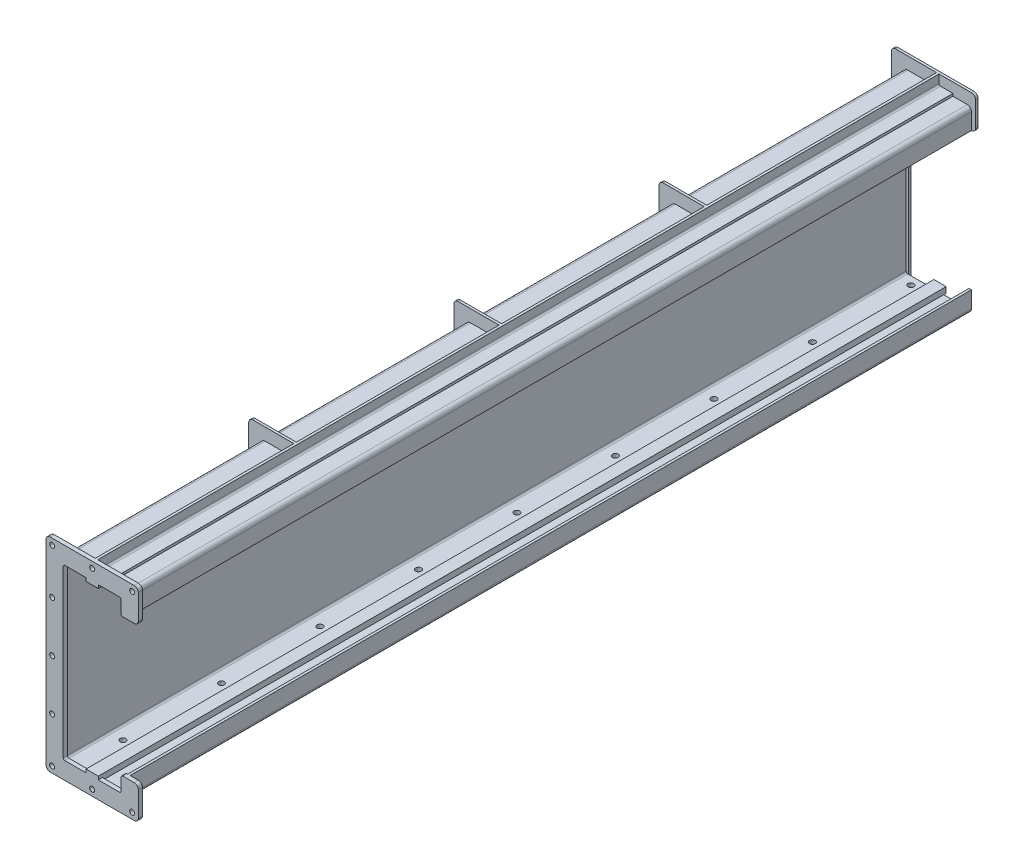
from build123d import *

# Parameters (mm, degrees)
EXTRUDE_1_DEPTH     = 2050
EXTRUDE_2_DEPTH     = 10
SKETCH_3_W          = 40
SKETCH_3_H          = 2050
EXTRUDE_3_DEPTH     = 6
SKETCH_4_W          = 6
SKETCH_4_H          = 2050
EXTRUDE_4_DEPTH     = 24
FILLET_1_R          = 4
FILLET_2_R          = 10
EXTRUDE_5_DEPTH     = 6
EXTRUDE_6_DEPTH     = 6
EXTRUDE_7_DEPTH     = 6
EXTRUDE_8_DEPTH     = 6
SKETCH_9_W          = 180
SKETCH_9_H          = 2056
EXTRUDE_9_DEPTH     = 6
SKETCH_10_W         = 30
SKETCH_10_H         = 14
EXTRUDE_10_DEPTH    = 2066
SKETCH_11_R         = 7
CUT_EXTRUDE_1_DEPTH = 37
SKETCH_13_R         = 6
CUT_EXTRUDE_2_DEPTH = 10


with BuildPart() as part:
    # 草图1 → 凸台-拉伸1 (new body)
    with BuildSketch(Plane.XY):
        with BuildLine():
            Line((10, 430), (155, 430))
            ThreePointArc((155, 430), (157.828427125, 428.828427125), (159, 426))
            Line((159, 426), (159, 386))
            Line((159, 386), (165, 386))
            Line((165, 386), (165, 426))
            ThreePointArc((165, 426), (162.071067812, 433.071067812), (155, 436))
            Line((155, 436), (10, 436))
            ThreePointArc((10, 436), (2.928932188, 433.071067812), (0, 426))
            Line((0, 426), (0, 10))
            ThreePointArc((0, 10), (2.928932188, 2.928932188), (10, 0))
            Line((10, 0), (155, 0))
            ThreePointArc((155, 0), (162.071067812, 2.928932188), (165, 10))
            Line((165, 10), (165, 50))
            Line((165, 50), (159, 50))
            Line((159, 50), (159, 10))
            ThreePointArc((159, 10), (157.828427125, 7.171572875), (155, 6))
            Line((155, 6), (10, 6))
            ThreePointArc((10, 6), (7.171572875, 7.171572875), (6, 10))
            Line((6, 10), (6, 426))
            ThreePointArc((6, 426), (7.171572875, 428.828427125), (10, 430))
        make_face()
    extrude(amount=EXTRUDE_1_DEPTH)



with BuildPart() as body_2:
    # 草图2 → 凸台-拉伸2 (new body)
    with BuildSketch(Plane.XY.offset(2050)):
        with BuildLine():
            Line((185, 466), (-20, 466))
            ThreePointArc((-20, 466), (-27.071067812, 463.071067812), (-30, 456))
            Line((-30, 456), (-30, -20))
            ThreePointArc((-30, -20), (-27.071067812, -27.071067812), (-20, -30))
            Line((-20, -30), (185, -30))
            ThreePointArc((185, -30), (192.071067812, -27.071067812), (195, -20))
            Line((195, -20), (195, 40))
            ThreePointArc((195, 40), (192.071067812, 47.071067812), (185, 50))
            Line((185, 50), (157, 50))
            ThreePointArc((157, 50), (154.171572875, 48.828427125), (153, 46))
            Line((153, 46), (153, 16))
            ThreePointArc((153, 16), (151.828427125, 13.171572875), (149, 12))
            Line((149, 12), (16, 12))
            ThreePointArc((16, 12), (13.171572875, 13.171572875), (12, 16))
            Line((12, 16), (12, 420))
            ThreePointArc((12, 420), (13.171572875, 422.828427125), (16, 424))
            Line((16, 424), (149, 424))
            ThreePointArc((149, 424), (151.828427125, 422.828427125), (153, 420))
            Line((153, 420), (153, 390))
            ThreePointArc((153, 390), (154.171572875, 387.171572875), (157, 386))
            Line((157, 386), (185, 386))
            ThreePointArc((185, 386), (192.071067812, 388.928932188), (195, 396))
            Line((195, 396), (195, 456))
            ThreePointArc((195, 456), (192.071067812, 463.071067812), (185, 466))
        make_face()
    extrude(amount=EXTRUDE_2_DEPTH)



with BuildPart() as body_3:
    # 草图3 → 凸台-拉伸3 (new body)
    with BuildSketch(Plane(origin=(0, 436, 0), x_dir=(1, 0, 0), z_dir=(0, 1, 0))):
        with Locations((100, -1025)):
            Rectangle(SKETCH_3_W, SKETCH_3_H)
    extrude(amount=EXTRUDE_3_DEPTH)


with BuildPart() as body_2_1:
    add(body_2.part)

    add(body_3.part)  # 凸台-拉伸4 merges body 3
    # 草图4 → 凸台-拉伸4 (add)
    with BuildSketch(Plane(origin=(0, 442, 0), x_dir=(1, 0, 0), z_dir=(0, 1, 0))):
        with Locations((83, -1025)):
            Rectangle(SKETCH_4_W, SKETCH_4_H)
    extrude(amount=EXTRUDE_4_DEPTH)

    # 圆角1
    fillet_1_edges = [body_2_1.edges().sort_by_distance(p)[0] for p in [
        (86, 442, 1025),
    ]]
    fillet(fillet_1_edges, radius=FILLET_1_R)

    # 圆角2
    fillet_2_edges = [body_2_1.edges().sort_by_distance(p)[0] for p in [
        (80, 436, 1025),
    ]]
    fillet(fillet_2_edges, radius=FILLET_2_R)


with BuildPart() as part_1:
    add(part.part)

    add(body_2_1.part)  # 凸台-拉伸5 merges body 2
    # 草图5 → 凸台-拉伸5 (add)
    with BuildSketch(Plane.XY.offset(1560)):
        with BuildLine():
            Line((0, 0), (-20, 0))
            ThreePointArc((-20, 0), (-27.071067812, 2.928932188), (-30, 10))
            Line((-30, 10), (-30, 456))
            ThreePointArc((-30, 456), (-27.071067812, 463.071067812), (-20, 466))
            Line((-20, 466), (80, 466))
            Line((80, 466), (80, 436))
            Line((80, 436), (10, 436))
            ThreePointArc((10, 436), (2.928932188, 433.071067812), (0, 426))
            Line((0, 426), (0, 0))
        make_face()
    extrude(amount=EXTRUDE_5_DEPTH)

    # 草图6 → 凸台-拉伸6 (add)
    with BuildSketch(Plane.XY.offset(1060)):
        with BuildLine():
            Line((0, 0), (0, 10))
            Line((0, 10), (0, 426))
            ThreePointArc((0, 426), (2.928932188, 433.071067812), (10, 436))
            Line((10, 436), (80, 436))
            Line((80, 436), (80, 446))
            Line((80, 446), (80, 466))
            Line((80, 466), (-20, 466))
            ThreePointArc((-20, 466), (-27.071067812, 463.071067812), (-30, 456))
            Line((-30, 456), (-30, 10))
            ThreePointArc((-30, 10), (-27.071067812, 2.928932188), (-20, 0))
            Line((-20, 0), (0, 0))
        make_face()
    extrude(amount=EXTRUDE_6_DEPTH)

    # 草图7 → 凸台-拉伸7 (add)
    with BuildSketch(Plane.XY.offset(560)):
        with BuildLine():
            Line((0, 10), (0, 426))
            ThreePointArc((0, 426), (2.928932188, 433.071067812), (10, 436))
            Line((10, 436), (80, 436))
            Line((80, 436), (80, 446))
            Line((80, 446), (80, 466))
            Line((80, 466), (-20, 466))
            ThreePointArc((-20, 466), (-27.071067812, 463.071067812), (-30, 456))
            Line((-30, 456), (-30, 10))
            ThreePointArc((-30, 10), (-27.071067812, 2.928932188), (-20, 0))
            Line((-20, 0), (0, 0))
            Line((0, 0), (0, 10))
        make_face()
    extrude(amount=EXTRUDE_7_DEPTH)

    # 草图8 → 凸台-拉伸8 (add)
    with BuildSketch(Plane(origin=(0, 0, 0), x_dir=(-1, 0, 0), z_dir=(0, 0, -1))):
        with BuildLine():
            Line((-12, 0), (30, 0))
            Line((30, 0), (30, 456))
            ThreePointArc((30, 456), (27.071067812, 463.071067812), (20, 466))
            Line((20, 466), (-165, 466))
            ThreePointArc((-165, 466), (-172.071067812, 463.071067812), (-175, 456))
            Line((-175, 456), (-175, 396))
            ThreePointArc((-175, 396), (-172.071067812, 388.928932188), (-165, 386))
            Line((-165, 386), (-157, 386))
            ThreePointArc((-157, 386), (-154.171572875, 387.171572875), (-153, 390))
            Line((-153, 390), (-153, 420))
            ThreePointArc((-153, 420), (-151.828427125, 422.828427125), (-149, 424))
            Line((-149, 424), (-16, 424))
            ThreePointArc((-16, 424), (-13.171572875, 422.828427125), (-12, 420))
            Line((-12, 420), (-12, 0))
        make_face()
    extrude(amount=EXTRUDE_8_DEPTH)

    # 草图9 → 凸台-拉伸9 (add)
    with BuildSketch(Plane.XZ):
        with Locations((60, 1022)):
            Rectangle(SKETCH_9_W, SKETCH_9_H)
    extrude(amount=EXTRUDE_9_DEPTH)

    # 草图10 → 凸台-拉伸10 (add)
    with BuildSketch(Plane.XY.offset(2060)):
        with Locations((82.5, 13)):
            Rectangle(SKETCH_10_W, SKETCH_10_H)
        with Locations((82.5, 423)):
            Rectangle(SKETCH_10_W, SKETCH_10_H)
    extrude(amount=-EXTRUDE_10_DEPTH)

    # 草图11 → 切除-拉伸1 (cut, through all)
    with BuildSketch(Plane(origin=(0, 6, 0), x_dir=(1, 0, 0), z_dir=(0, 1, 0))):
        with Locations((37.5, -20)):
            Circle(SKETCH_11_R)
        with Locations((127.5, -20)):
            Circle(SKETCH_11_R)
        with Locations((37.5, -260)):
            Circle(SKETCH_11_R)
        with Locations((127.5, -260)):
            Circle(SKETCH_11_R)
        with Locations((37.5, -500)):
            Circle(SKETCH_11_R)
        with Locations((127.5, -500)):
            Circle(SKETCH_11_R)
        with Locations((37.5, -740)):
            Circle(SKETCH_11_R)
        with Locations((127.5, -740)):
            Circle(SKETCH_11_R)
        with Locations((37.5, -980)):
            Circle(SKETCH_11_R)
        with Locations((127.5, -980)):
            Circle(SKETCH_11_R)
        with Locations((37.5, -1220)):
            Circle(SKETCH_11_R)
        with Locations((127.5, -1220)):
            Circle(SKETCH_11_R)
        with Locations((37.5, -1460)):
            Circle(SKETCH_11_R)
        with Locations((127.5, -1460)):
            Circle(SKETCH_11_R)
        with Locations((37.5, -1700)):
            Circle(SKETCH_11_R)
        with Locations((127.5, -1700)):
            Circle(SKETCH_11_R)
        with Locations((37.5, -1940)):
            Circle(SKETCH_11_R)
        with Locations((127.5, -1940)):
            Circle(SKETCH_11_R)
    extrude(amount=-CUT_EXTRUDE_1_DEPTH, mode=Mode.SUBTRACT)

    # 草图13 → 切除-拉伸2 (cut)
    with BuildSketch(Plane.XY.offset(2060)):
        with Locations((82.5, -15)):
            Circle(SKETCH_13_R)
        with Locations((-15, -15)):
            Circle(SKETCH_13_R)
        with Locations((180, -15)):
            Circle(SKETCH_13_R)
        with Locations((-15, 218)):
            Circle(SKETCH_13_R)
        with Locations((-15, 451)):
            Circle(SKETCH_13_R)
        with Locations((82.5, 451)):
            Circle(SKETCH_13_R)
        with Locations((180, 451)):
            Circle(SKETCH_13_R)
        with Locations((-15, 341)):
            Circle(SKETCH_13_R)
        with Locations((-15, 95)):
            Circle(SKETCH_13_R)
    extrude(amount=-CUT_EXTRUDE_2_DEPTH, mode=Mode.SUBTRACT)


solid = part_1.part
